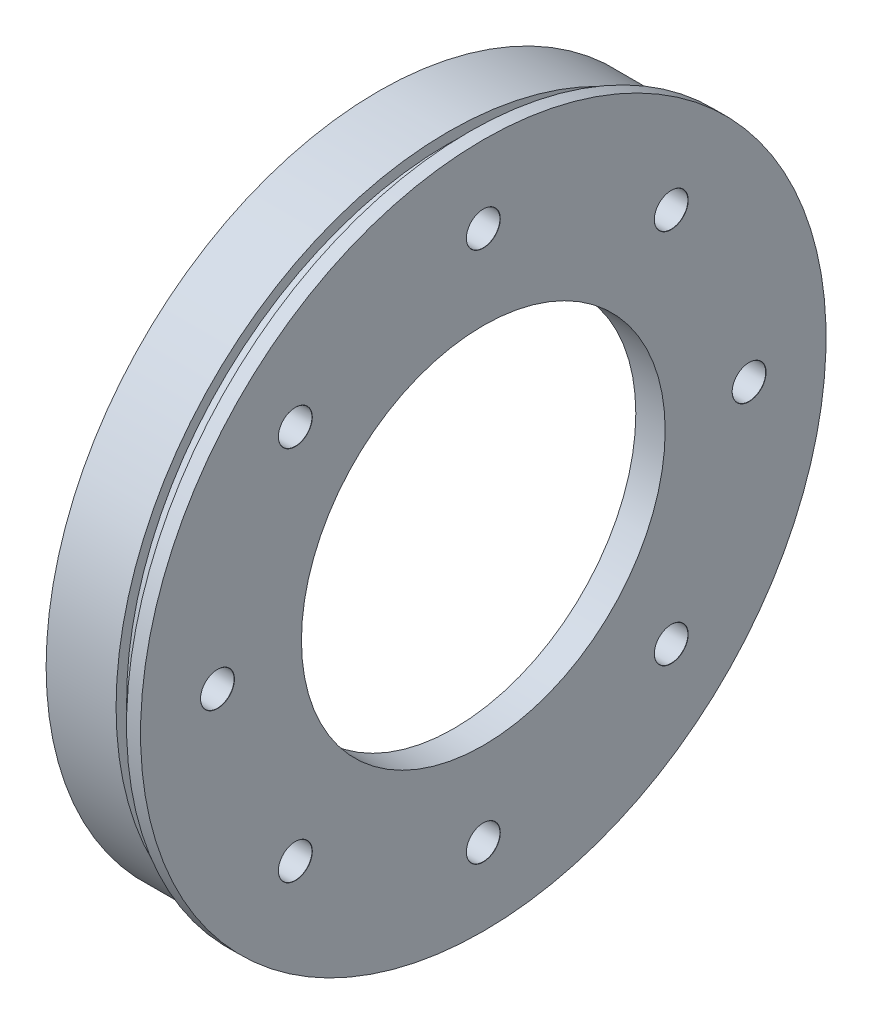
from build123d import *

# Parameters (mm, degrees)
CIRPATTERN1_COUNT  = 8
SKETCH4_R          = 28
CUT_EXTRUDE1_DEPTH = 0.8


with BuildPart() as part:
    # Sketch1 → Revolve1 (revolve)
    with BuildSketch(Plane.XY):
        Polygon((-15, 47.5), (-5, 47.5), (-5, 46), (-2, 46), (-2, 49), (0, 49), (0, 26), (-5, 26), (-5, 42.8), (-15, 42.8), align=None)
    revolve(axis=Axis((0, 0, 0), (-1, 0, 0)))

    # Sketch3 → M4 Clearance Hole1 (revolve, cut)
    with BuildSketch(Plane(origin=(0, 0, 38), x_dir=(0, 0, -1), z_dir=(0, 1, 0))):
        Polygon((0, 0), (0, 22.442065486), (2.4, 21), (2.4, 0.025), (2.425, 0), align=None)
    m4_clearance_hole1 = revolve(axis=Axis((6.35, 0, 38), (-1, 0, 0)), mode=Mode.SUBTRACT)

    # CirPattern1: M4 Clearance Hole1 ×8 about axis
    cirpattern1_axis = Axis((0, 0, 0), (1, 0, 0))
    for i in range(1, CIRPATTERN1_COUNT):
        add(m4_clearance_hole1.rotate(cirpattern1_axis, i * 360 / CIRPATTERN1_COUNT), mode=Mode.SUBTRACT)

    # Sketch4 → Cut-Extrude1 (cut)
    with BuildSketch(Plane.ZY.offset(5)):
        Circle(SKETCH4_R)
    extrude(amount=-CUT_EXTRUDE1_DEPTH, mode=Mode.SUBTRACT)


solid = part.part
